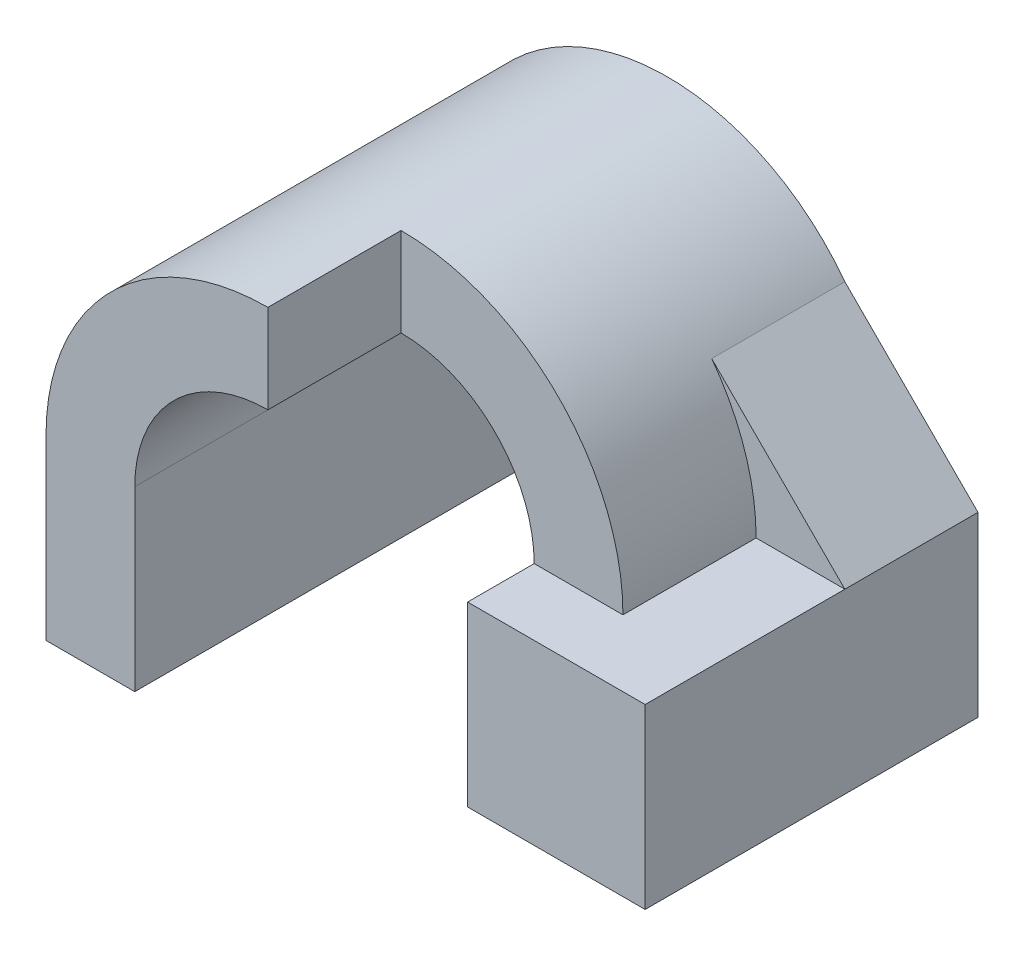
from build123d import *

# Parameters (mm, degrees)
BOSS_EXTRUDE1_DEPTH = 9
SKETCH2_W           = 5
SKETCH2_H           = 9
CUT_EXTRUDE1_DEPTH  = 3
BOSS_EXTRUDE2_DEPTH = 3
SKETCH4_W           = 4
SKETCH4_H           = 4
BOSS_EXTRUDE3_DEPTH = 4.5


with BuildPart() as part:
    # Sketch1 → Boss-Extrude1 (new body)
    with BuildSketch(Plane.XY):
        with BuildLine():
            Line((3, 0), (3, -4))
            Line((3, -4), (5, -4))
            Line((5, -4), (5, 0))
            ThreePointArc((5, 0), (0, 5), (-5, 0))
            Line((-5, 0), (-5, -4))
            Line((-5, -4), (-3, -4))
            Line((-3, -4), (-3, 0))
            ThreePointArc((-3, 0), (0, 3), (3, 0))
        make_face()
    extrude(amount=BOSS_EXTRUDE1_DEPTH)

    # Sketch2 → Cut-Extrude1 (cut)
    with BuildSketch(Plane.XY.offset(9)):
        with Locations((2.5, 0.5)):
            Rectangle(SKETCH2_W, SKETCH2_H)
    extrude(amount=-CUT_EXTRUDE1_DEPTH, mode=Mode.SUBTRACT)



with BuildPart() as body_2:
    # Sketch3 → Boss-Extrude2 (new body)
    with BuildSketch(Plane(origin=(0, 0, 0), x_dir=(-1, 0, 0), z_dir=(0, 0, -1))):
        with BuildLine():
            Line((-5, -4), (-7, -4))
            Line((-7, -4), (-7, 0))
            Line((-7, 0), (-4, 3))
            ThreePointArc((-4, 3), (-4.74341649, 1.58113883), (-5, 0))
            Line((-5, 0), (-5, -4))
        make_face()
    extrude(amount=-BOSS_EXTRUDE2_DEPTH)


with BuildPart() as part_1:
    add(part.part)

    add(body_2.part)  # Boss-Extrude3 merges body 2
    # Sketch4 → Boss-Extrude3 (add)
    with BuildSketch(Plane.XY.offset(3)):
        with Locations((5, -2)):
            Rectangle(SKETCH4_W, SKETCH4_H)
    extrude(amount=BOSS_EXTRUDE3_DEPTH)


solid = part_1.part
